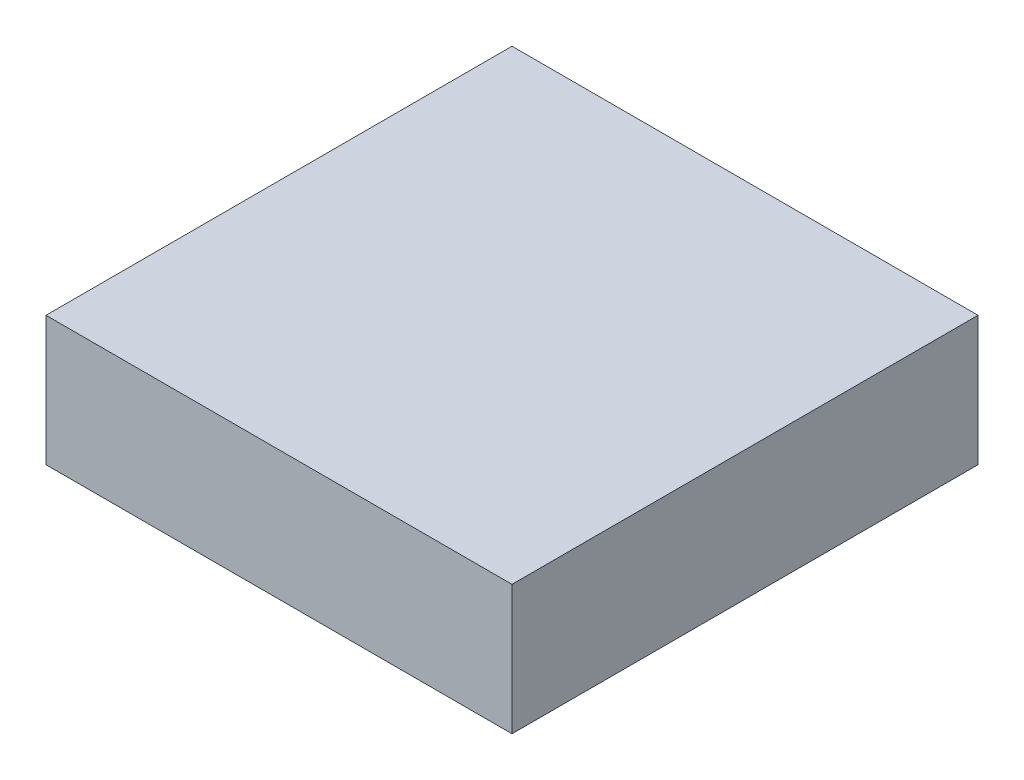
from build123d import *

# Parameters (mm, degrees)
SKETCH1_W           = 36
SKETCH1_H           = 36
BOSS_EXTRUDE1_DEPTH = 10


with BuildPart() as part:
    # Sketch1 → Boss-Extrude1 (new body)
    with BuildSketch(Plane(origin=(0, 0, 0), x_dir=(1, 0, 0), z_dir=(0, 1, 0))):
        Rectangle(SKETCH1_W, SKETCH1_H)
    extrude(amount=BOSS_EXTRUDE1_DEPTH)


solid = part.part
